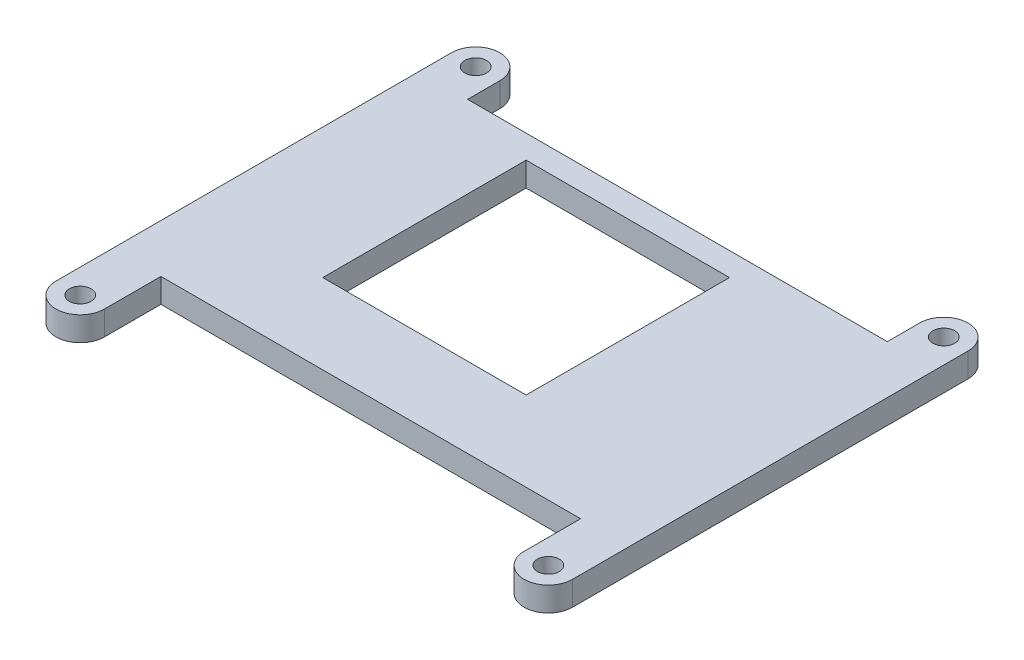
from build123d import *

# Parameters (mm, degrees)
SKETCH_1_R      = 1.35
SKETCH_1_W      = 25.2
SKETCH_1_H      = 25.2
EXTRUDE_1_DEPTH = 3


with BuildPart() as part:
    # 草图1 → 凸台-拉伸1 (new body)
    with BuildSketch(Plane(origin=(0, 0, 0), x_dir=(1, 0, 0), z_dir=(0, 1, 0))):
        with BuildLine():
            Line((-28.75, 19.5), (-28.75, -29.5))
            ThreePointArc((-28.75, -29.5), (-25.75, -32.5), (-22.75, -29.5))
            Line((-22.75, -29.5), (-22.75, -22.5))
            Line((-22.75, -22.5), (29.25, -22.5))
            Line((29.25, -22.5), (29.25, -29.5))
            ThreePointArc((29.25, -29.5), (32.25, -32.5), (35.25, -29.5))
            Line((35.25, -29.5), (35.25, 19.5))
            ThreePointArc((35.25, 19.5), (32.25, 22.5), (29.25, 19.5))
            Line((29.25, 19.5), (29.25, 15.5))
            Line((29.25, 15.5), (-22.75, 15.5))
            Line((-22.75, 15.5), (-22.75, 19.5))
            ThreePointArc((-22.75, 19.5), (-25.75, 22.5), (-28.75, 19.5))
        make_face()
        with Locations((-25.75, 19.5)):
            Circle(SKETCH_1_R, mode=Mode.SUBTRACT)
        with Locations((-25.75, -29.5)):
            Circle(SKETCH_1_R, mode=Mode.SUBTRACT)
        with Locations((32.25, 19.5)):
            Circle(SKETCH_1_R, mode=Mode.SUBTRACT)
        with Locations((32.25, -29.5)):
            Circle(SKETCH_1_R, mode=Mode.SUBTRACT)
        Rectangle(SKETCH_1_W, SKETCH_1_H, mode=Mode.SUBTRACT)
    extrude(amount=EXTRUDE_1_DEPTH)


solid = part.part
